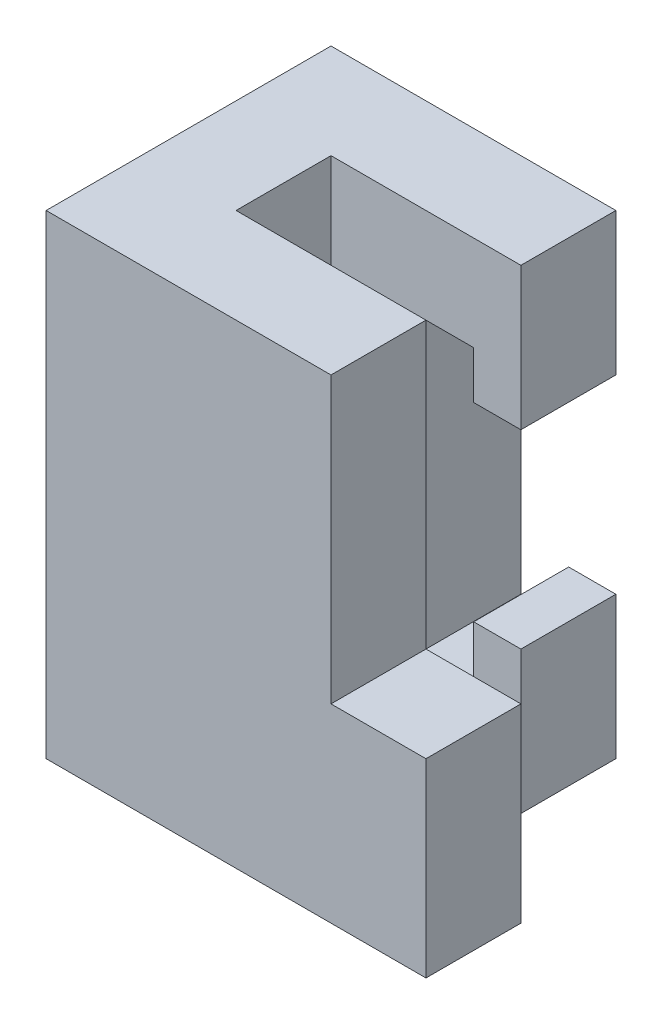
from build123d import *

# Parameters (mm, degrees)
BOSS_EXTRUDE1_DEPTH = 63.5
CUT_EXTRUDE3_DEPTH  = 12.7
SKETCH3_W           = 12.7
SKETCH3_H           = 25.4
BOSS_EXTRUDE2_DEPTH = 12.7


with BuildPart() as part:
    # Sketch1 → Boss-Extrude1 (new body)
    with BuildSketch(Plane(origin=(0, 0, 0), x_dir=(1, 0, 0), z_dir=(0, 1, 0))):
        Polygon((0, 0), (25.4, 0), (25.4, -12.7), (-12.7, -12.7), (-12.7, 25.4), (25.4, 25.4), (25.4, 12.7), (0, 12.7), align=None)
    extrude(amount=BOSS_EXTRUDE1_DEPTH)

    # Sketch2 → Cut-Extrude3 (cut)
    with BuildSketch(Plane(origin=(0, 0, -25.4), x_dir=(-1, 0, 0), z_dir=(0, 0, -1))):
        Polygon((-25.4, 44.45), (-19.05, 44.45), (-19.05, 50.8), (-12.7, 50.8), (-12.7, 12.7), (-19.088668149, 12.7), (-19.088668149, 19.05), (-25.4, 19.05), align=None)
    extrude(amount=-CUT_EXTRUDE3_DEPTH, mode=Mode.SUBTRACT)

    # Sketch3 → Boss-Extrude2 (add)
    with BuildSketch(Plane(origin=(25.4, 0, 0), x_dir=(0, 0, -1), z_dir=(1, 0, 0))):
        with Locations((-6.35, 12.7)):
            Rectangle(SKETCH3_W, SKETCH3_H)
    extrude(amount=BOSS_EXTRUDE2_DEPTH)


solid = part.part
